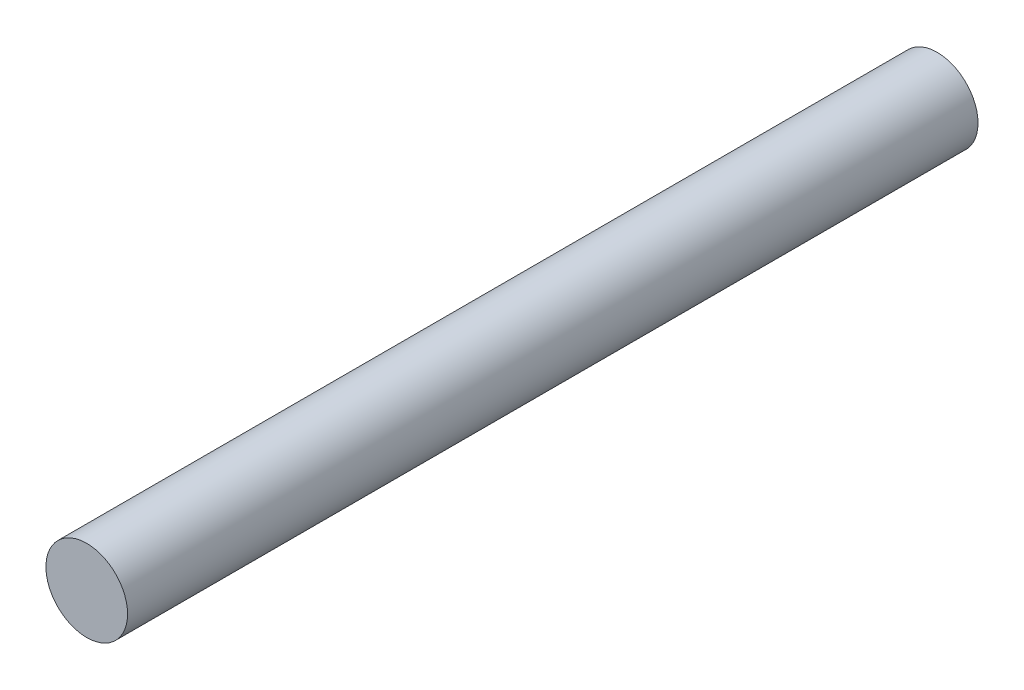
from build123d import *

# Parameters (mm, degrees)
SKETCH1_R           = 24
BOSS_EXTRUDE1_DEPTH = 500


with BuildPart() as part:
    # Sketch1 → Boss-Extrude1 (new body)
    with BuildSketch(Plane.XY):
        Circle(SKETCH1_R)
    extrude(amount=BOSS_EXTRUDE1_DEPTH)


solid = part.part
